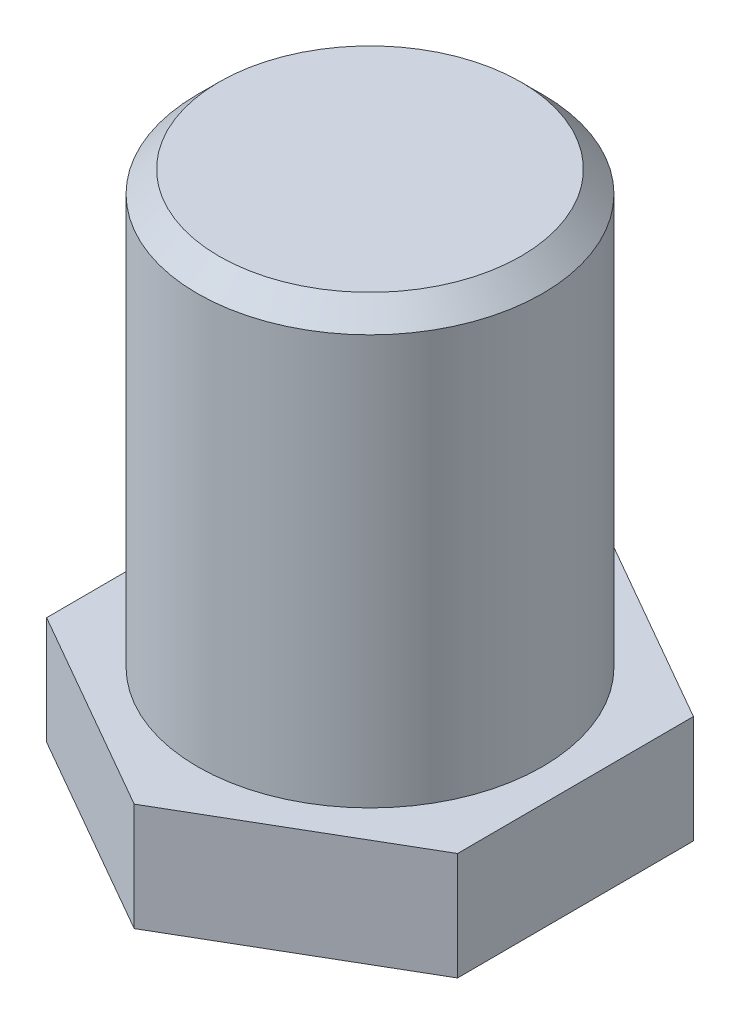
from build123d import *

# Parameters (mm, degrees)
BOSS_EXTRUDE1_DEPTH = 5
SKETCH2_R           = 8
BOSS_EXTRUDE2_DEPTH = 25
CHAMFER1_SIZE       = 1


with BuildPart() as part:
    # Sketch1 → Boss-Extrude1 (new body)
    with BuildSketch(Plane(origin=(0, 0, 0), x_dir=(1, 0, 0), z_dir=(0, 1, 0))):
        Polygon((9.517177276, -5.454967463), (9.482729038, 5.514633562), (-0.034448238, 10.969601025), (-9.517177276, 5.454967463), (-9.482729038, -5.514633562), (0.034448238, -10.969601025), align=None)
    extrude(amount=BOSS_EXTRUDE1_DEPTH)

    # Sketch2 → Boss-Extrude2 (add)
    with BuildSketch(Plane(origin=(0, 0, 0), x_dir=(1, 0, 0), z_dir=(0, 1, 0))):
        Circle(SKETCH2_R)
    extrude(amount=BOSS_EXTRUDE2_DEPTH)

    # Chamfer1
    chamfer1_edges = [part.edges().sort_by_distance(p)[0] for p in [
        (-8, 25, 0),
    ]]
    chamfer(chamfer1_edges, length=CHAMFER1_SIZE)


solid = part.part
